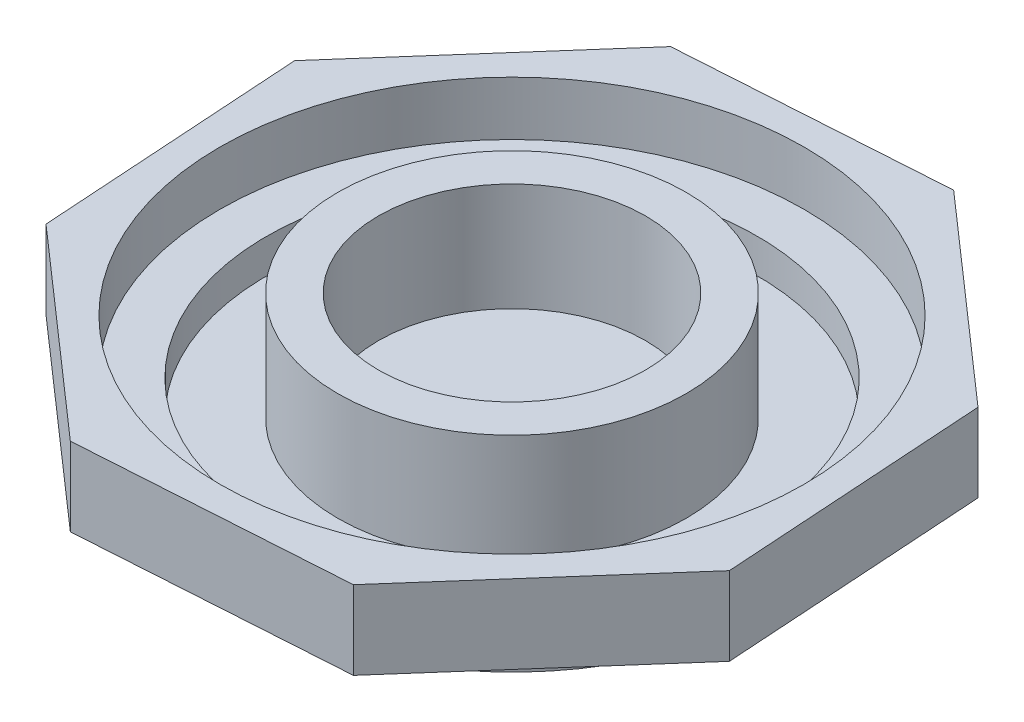
from build123d import *

# Parameters (mm, degrees)
SKETCH1_R           = 13.75
BOSS_EXTRUDE1_DEPTH = 2
BOSS_EXTRUDE2_DEPTH = 4
SKETCH3_R           = 14.875
CUT_EXTRUDE1_DEPTH  = 2.75
SKETCH4_R           = 12.5
CUT_EXTRUDE2_DEPTH  = 1.75
SKETCH5_R           = 8.875
BOSS_EXTRUDE3_DEPTH = 5.5
SKETCH6_R           = 6.8
CUT_EXTRUDE3_DEPTH  = 5.5


with BuildPart() as part:
    # Sketch1 → Boss-Extrude1 (new body)
    with BuildSketch(Plane(origin=(0, 0, 0), x_dir=(1, 0, 0), z_dir=(0, 1, 0))):
        Circle(SKETCH1_R)
    extrude(amount=BOSS_EXTRUDE1_DEPTH)

    # Sketch2 → Boss-Extrude2 (add)
    with BuildSketch(Plane(origin=(0, 2, 0), x_dir=(1, 0, 0), z_dir=(0, 1, 0))):
        Polygon((16.778956996, -5.710769223), (15.902637917, 7.82639063), (5.710769223, 16.778956996), (-7.82639063, 15.902637917), (-16.778956996, 5.710769223), (-15.902637917, -7.82639063), (-5.710769223, -16.778956996), (7.82639063, -15.902637917), align=None)
    extrude(amount=BOSS_EXTRUDE2_DEPTH)

    # Sketch3 → Cut-Extrude1 (cut)
    with BuildSketch(Plane(origin=(0, 6, 0), x_dir=(1, 0, 0), z_dir=(0, 1, 0))):
        Circle(SKETCH3_R)
    extrude(amount=-CUT_EXTRUDE1_DEPTH, mode=Mode.SUBTRACT)

    # Sketch4 → Cut-Extrude2 (cut)
    with BuildSketch(Plane(origin=(0, 3.25, 0), x_dir=(1, 0, 0), z_dir=(0, 1, 0))):
        Circle(SKETCH4_R)
    extrude(amount=-CUT_EXTRUDE2_DEPTH, mode=Mode.SUBTRACT)

    # Sketch5 → Boss-Extrude3 (add)
    with BuildSketch(Plane(origin=(0, 1.5, 0), x_dir=(1, 0, 0), z_dir=(0, 1, 0))):
        Circle(SKETCH5_R)
    extrude(amount=BOSS_EXTRUDE3_DEPTH)

    # Sketch6 → Cut-Extrude3 (cut)
    with BuildSketch(Plane(origin=(0, 7, 0), x_dir=(1, 0, 0), z_dir=(0, 1, 0))):
        Circle(SKETCH6_R)
    extrude(amount=-CUT_EXTRUDE3_DEPTH, mode=Mode.SUBTRACT)


solid = part.part
